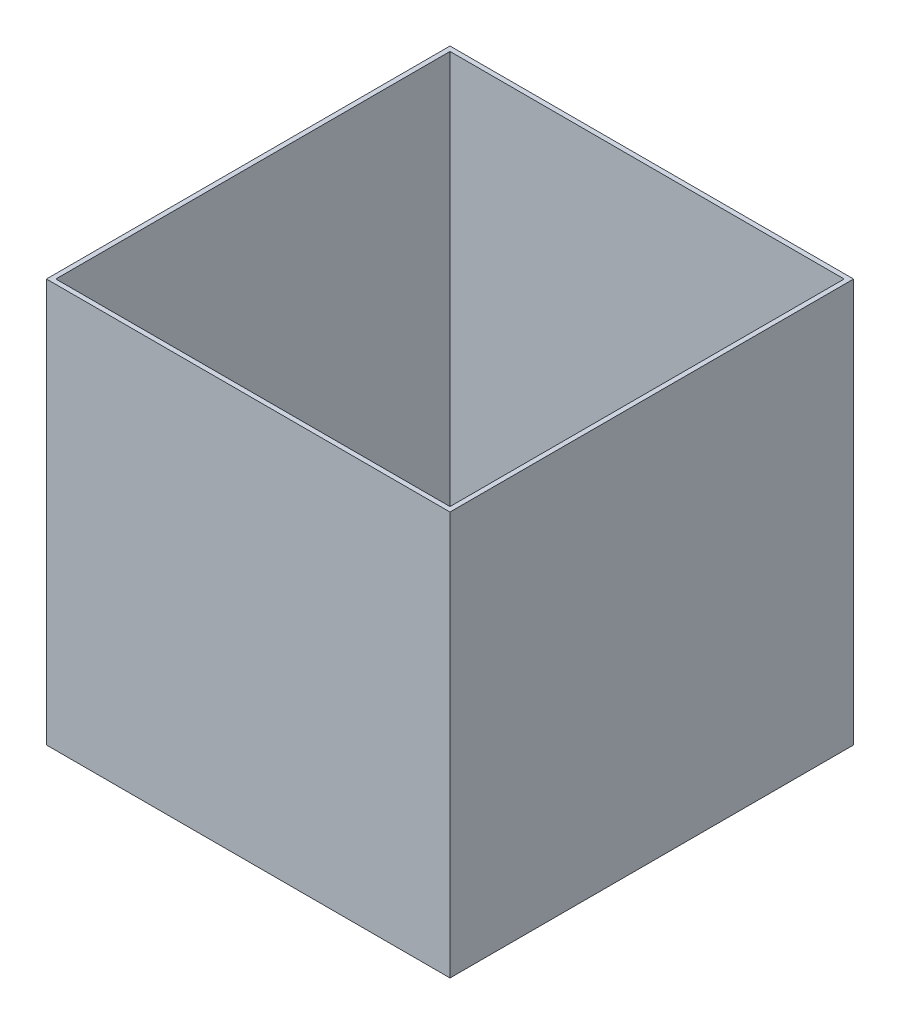
from build123d import *

# Parameters (mm, degrees)
SKETCH1_W           = 60
SKETCH1_H           = 60
BOSS_EXTRUDE1_DEPTH = 60
SHELL1_T            = -0.7


with BuildPart() as part:
    # Sketch1 → Boss-Extrude1 (new body)
    with BuildSketch(Plane(origin=(0, 0, 0), x_dir=(1, 0, 0), z_dir=(0, 1, 0))):
        Rectangle(SKETCH1_W, SKETCH1_H)
    extrude(amount=BOSS_EXTRUDE1_DEPTH)

    # Shell1
    shell1_openings = [part.faces().sort_by_distance(p)[0] for p in [
        (0, 60, 0),
    ]]
    offset(amount=SHELL1_T, openings=shell1_openings, kind=Kind.INTERSECTION)


solid = part.part
